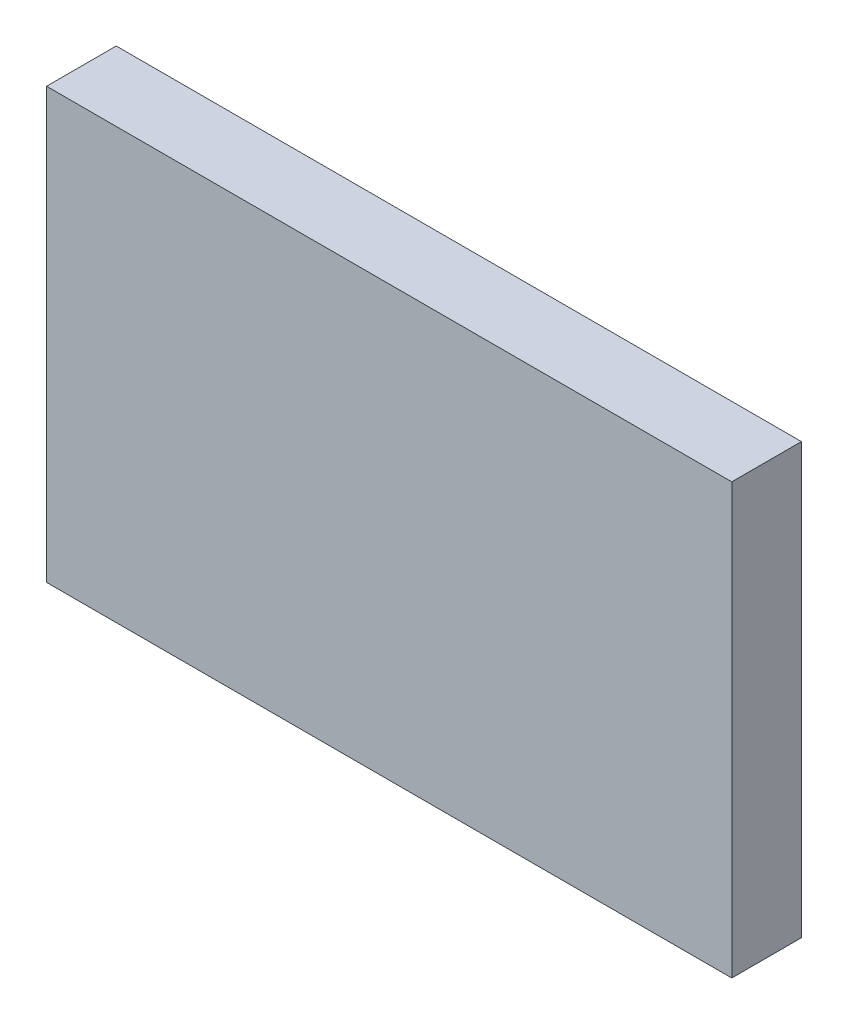
from build123d import *

# Parameters (mm, degrees)
SKETCH1_W           = 59
SKETCH1_H           = 37
BOSS_EXTRUDE1_DEPTH = 6


with BuildPart() as part:
    # Sketch1 → Boss-Extrude1 (new body)
    with BuildSketch(Plane.XY):
        Rectangle(SKETCH1_W, SKETCH1_H)
    extrude(amount=BOSS_EXTRUDE1_DEPTH)


solid = part.part
